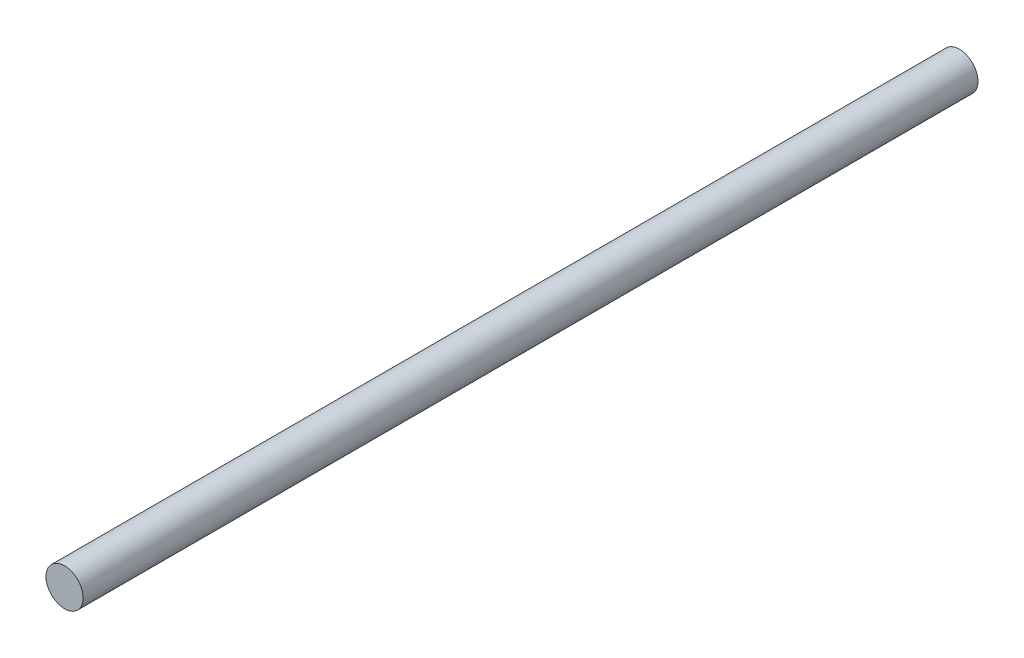
from build123d import *

# Parameters (mm, degrees)
SKETCH1_R           = 6
BOSS_EXTRUDE1_DEPTH = 288.5


with BuildPart() as part:
    # Sketch1 → Boss-Extrude1 (new body)
    with BuildSketch(Plane.XY):
        Circle(SKETCH1_R)
    extrude(amount=BOSS_EXTRUDE1_DEPTH)


solid = part.part
